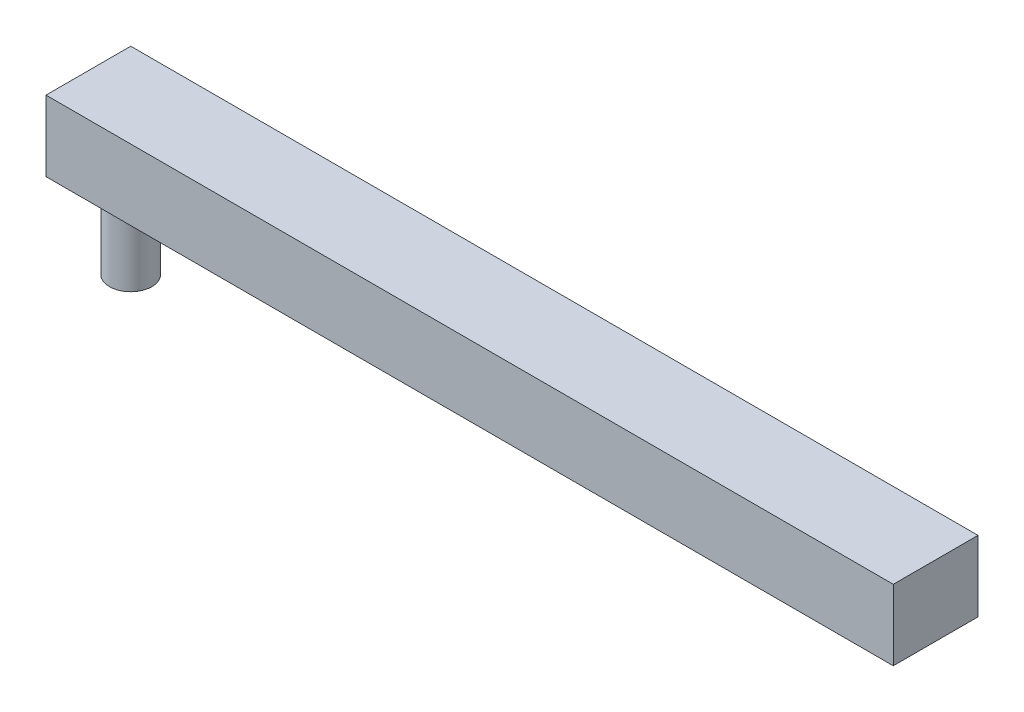
from build123d import *

# Parameters (mm, degrees)
BOSS_EXTRUDE1_DEPTH = 5
SKETCH2_R           = 1.5
BOSS_EXTRUDE2_DEPTH = 6


with BuildPart() as part:
    # Sketch1 → Boss-Extrude1 (new body)
    with BuildSketch(Plane(origin=(0, -9.928470523, 0), x_dir=(1, 0, 0), z_dir=(0, 1, 0))):
        Polygon((52.683579598, -6.935769114), (-2.820579734, -6.935769114), (-7.316420402, -6.935769114), (-7.316420402, -0.935769114), (52.683579598, -0.935769114), align=None)
    extrude(amount=BOSS_EXTRUDE1_DEPTH)

    # Sketch2 → Boss-Extrude2 (add)
    with BuildSketch(Plane.XZ.offset(9.928470523)):
        with Locations((-4.316420402, 3.935769114)):
            Circle(SKETCH2_R)
    extrude(amount=BOSS_EXTRUDE2_DEPTH)


solid = part.part
